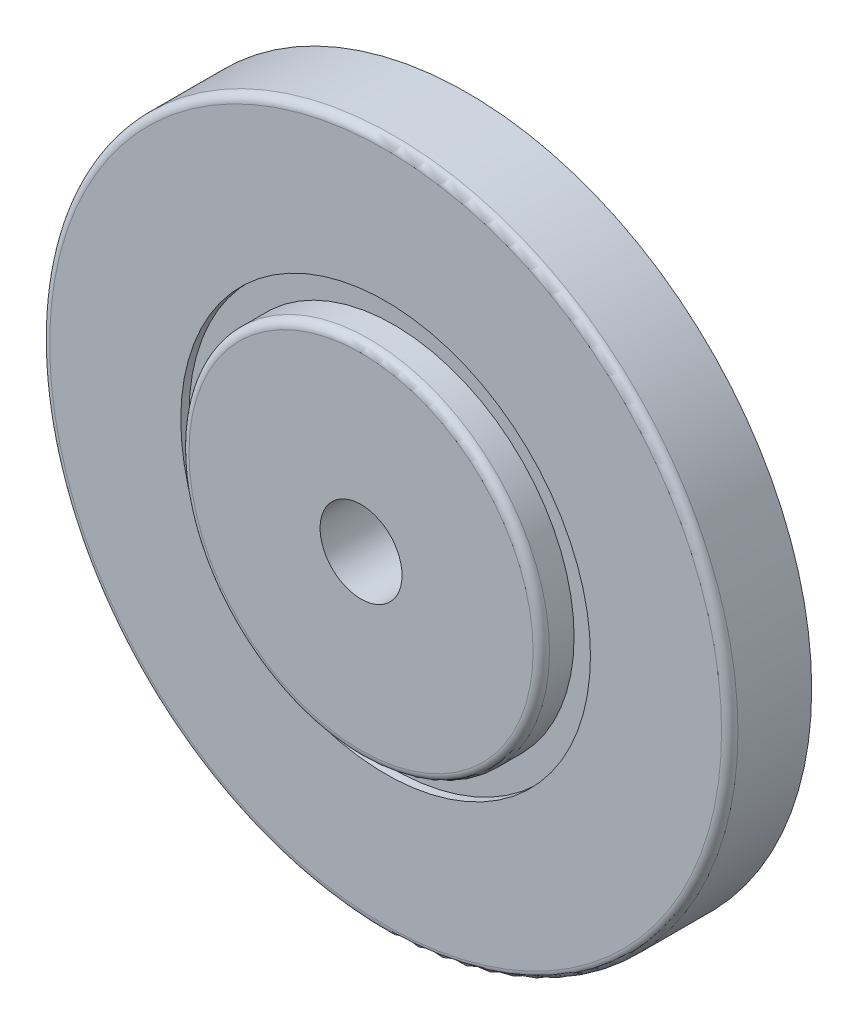
from build123d import *

# Parameters (mm, degrees)
CROQUIS1_R              = 21
SALIENTE_EXTRUIR1_DEPTH = 5
CROQUIS2_R              = 12.5
CORTAR_EXTRUIR1_DEPTH   = 0.5
CROQUIS3_R              = 11
SALIENTE_EXTRUIR2_DEPTH = 2
CROQUIS4_R              = 2.5
CORTAR_EXTRUIR2_DEPTH   = 7.5
REDONDEO1_R             = 0.5
REDONDEO2_R             = 0.5


with BuildPart() as part:
    # Croquis1 → Saliente-Extruir1 (new body)
    with BuildSketch(Plane.XY):
        Circle(CROQUIS1_R)
    extrude(amount=SALIENTE_EXTRUIR1_DEPTH)

    # Croquis2 → Cortar-Extruir1 (cut)
    with BuildSketch(Plane.XY.offset(5)):
        Circle(CROQUIS2_R)
    extrude(amount=-CORTAR_EXTRUIR1_DEPTH, mode=Mode.SUBTRACT)

    # Croquis3 → Saliente-Extruir2 (add)
    with BuildSketch(Plane.XY.offset(4.5)):
        Circle(CROQUIS3_R)
    extrude(amount=SALIENTE_EXTRUIR2_DEPTH)

    # Croquis4 → Cortar-Extruir2 (cut, through all)
    with BuildSketch(Plane.XY.offset(6.5)):
        Circle(CROQUIS4_R)
    extrude(amount=-CORTAR_EXTRUIR2_DEPTH, mode=Mode.SUBTRACT)

    # Redondeo1
    redondeo1_edges = [part.edges().sort_by_distance(p)[0] for p in [
        (-21, 0, 5),
    ]]
    fillet(redondeo1_edges, radius=REDONDEO1_R)

    # Redondeo2
    redondeo2_edges = [part.edges().sort_by_distance(p)[0] for p in [
        (-11, 0, 6.5),
    ]]
    fillet(redondeo2_edges, radius=REDONDEO2_R)


solid = part.part
